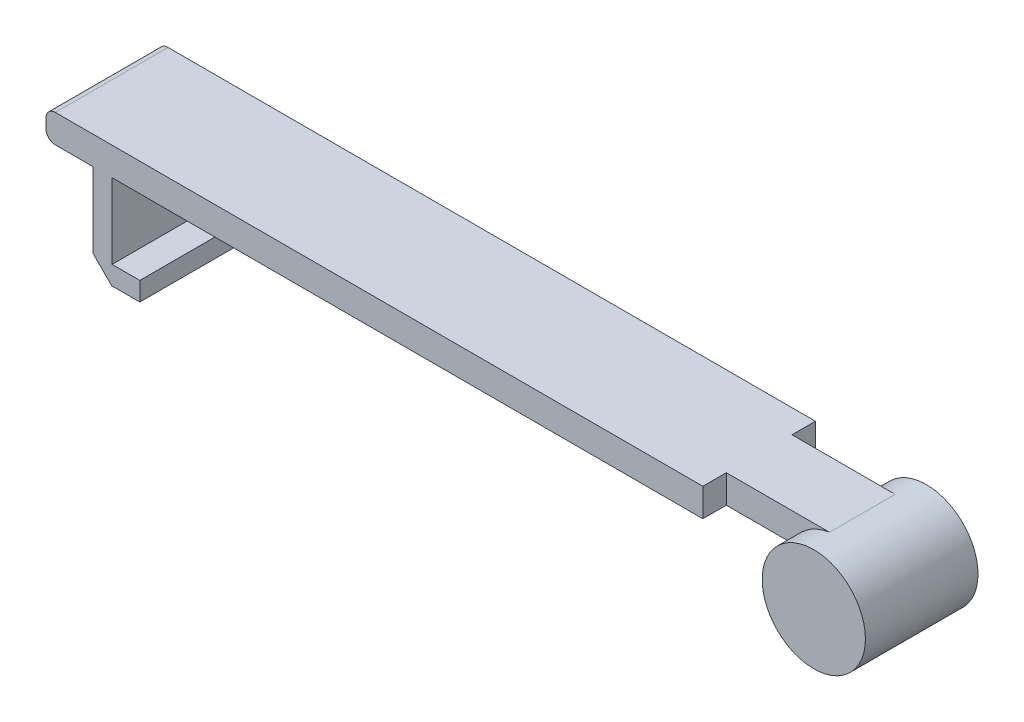
from build123d import *

# Parameters (mm, degrees)
ESQUISSE1_R        = 5.5
BOSS_EXTRU_1_DEPTH = 12
ESQUISSE2_W        = 12
ESQUISSE2_H        = 3
BOSS_EXTRU_2_DEPTH = 7
BOSS_EXTRU_3_DEPTH = 12
CHANFREIN1_SIZE    = 2
CONG_1_R           = 1


with BuildPart() as part:
    # Esquisse1 → Boss.-Extru.1 (new body)
    with BuildSketch(Plane.XY):
        with Locations((25.477220372, 0.406206053)):
            Circle(ESQUISSE1_R)
    extrude(amount=BOSS_EXTRU_1_DEPTH)

    # Esquisse2 → Boss.-Extru.2 (add)
    with BuildSketch(Plane.XY.offset(2.5)):
        with Locations((19.654430588, 4.343698911)):
            Rectangle(ESQUISSE2_W, ESQUISSE2_H)
    extrude(amount=BOSS_EXTRU_2_DEPTH)

    # Esquisse3 → Boss.-Extru.3 (add)
    with BuildSketch(Plane.XY):
        Polygon((-49.298156478, 2.843698911), (13.654430588, 2.843698911), (13.654430588, 5.843698911), (-56.345569412, 5.843698911), (-56.345569412, 2.843698911), (-51.345569412, 2.843698911), (-51.345569412, -7.156301089), (-46.345569412, -7.156301089), (-46.345569412, -5.156301089), (-49.298156478, -5.156301089), align=None)
    extrude(amount=BOSS_EXTRU_3_DEPTH)

    # Chanfrein1
    chanfrein1_edges = [part.edges().sort_by_distance(p)[0] for p in [
        (-51.345569412, -7.156301089, 6),
    ]]
    chamfer(chanfrein1_edges, length=CHANFREIN1_SIZE)

    # Congé1
    cong_1_edges = [part.edges().sort_by_distance(p)[0] for p in [
        (-56.345569412, 5.843698911, 6),
        (-56.345569412, 2.843698911, 6),
    ]]
    fillet(cong_1_edges, radius=CONG_1_R)


solid = part.part
